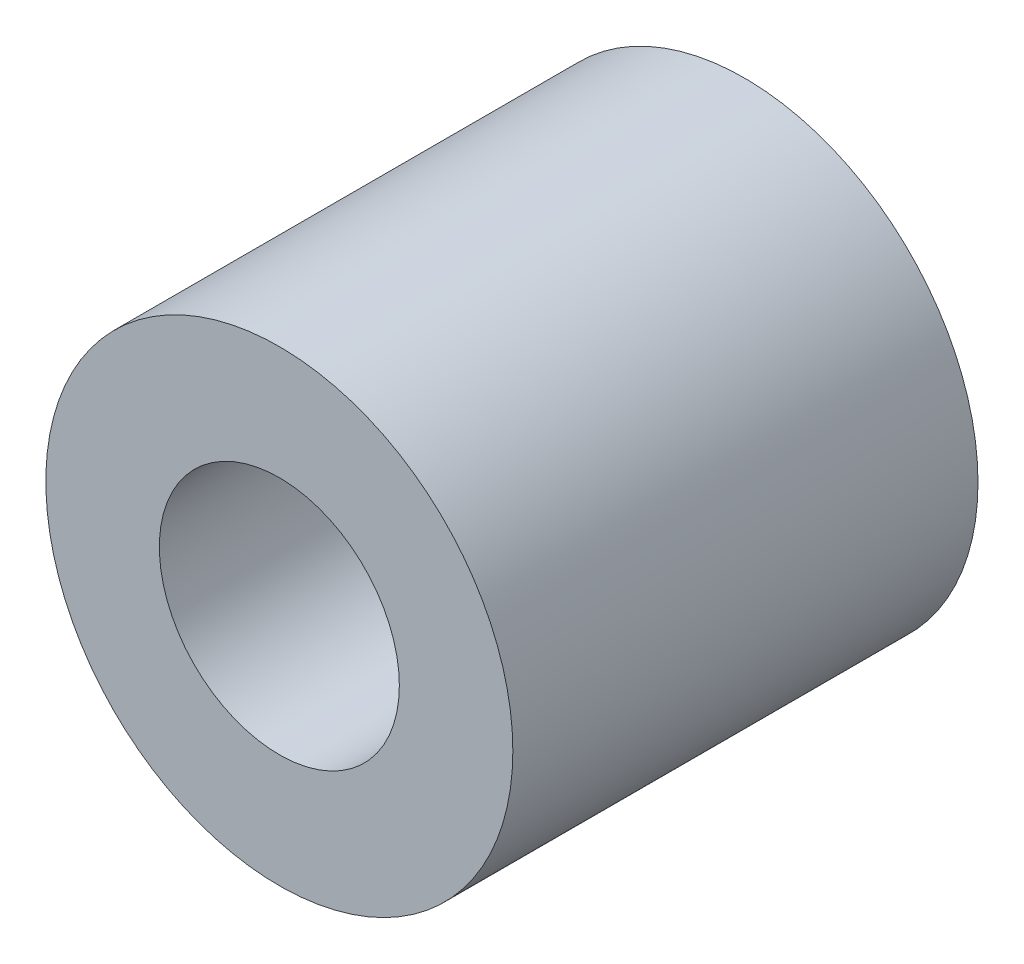
from build123d import *

# Parameters (mm, degrees)
SKETCH1_R      = 3.1877
SKETCH1_R_2    = 1.6383
EXTRUDE1_DEPTH = 3.175


with BuildPart() as part:
    # Sketch1 → Extrude1 (new body, symmetric)
    with BuildSketch(Plane.XY):
        Circle(SKETCH1_R)
        Circle(SKETCH1_R_2, mode=Mode.SUBTRACT)
    extrude(amount=EXTRUDE1_DEPTH, both=True)


solid = part.part
